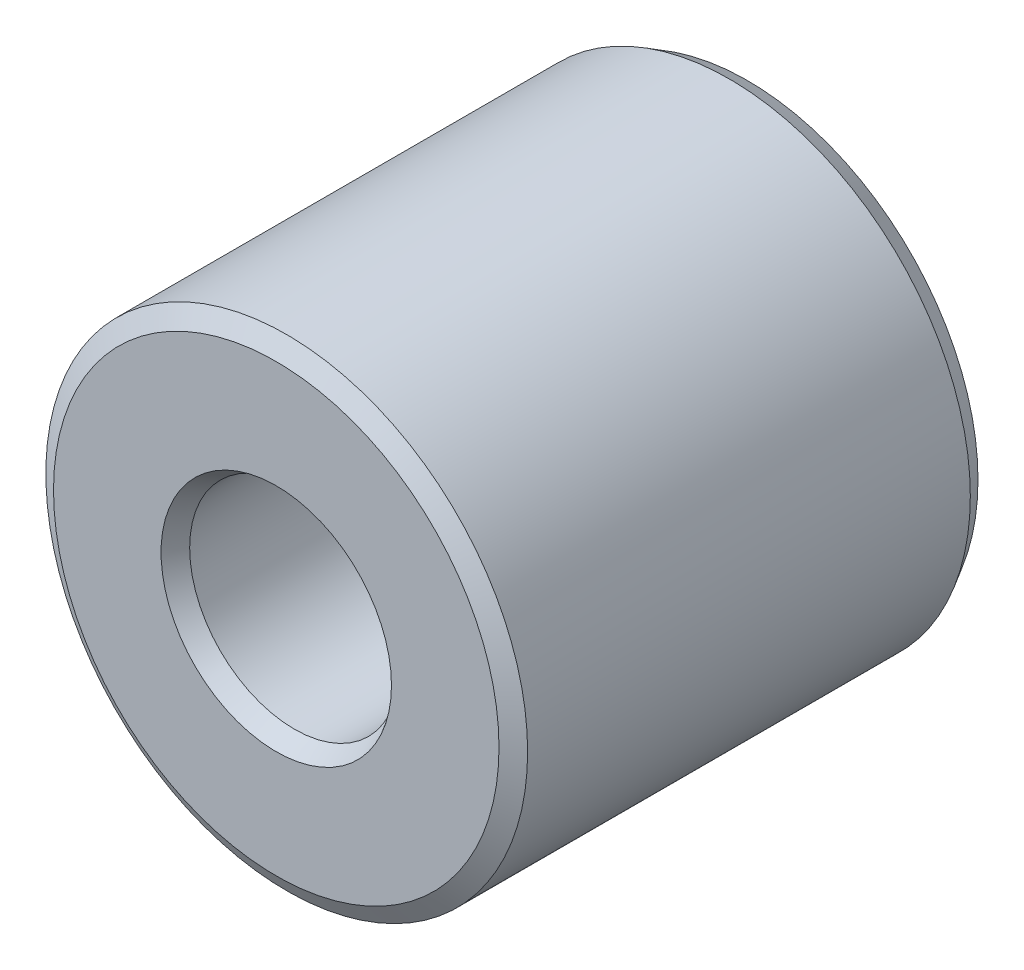
from build123d import *
from OCP.BRepFilletAPI import BRepFilletAPI_MakeChamfer

# Parameters (mm, degrees)
SZKIC1_R                    = 2.3
SZKIC1_R_2                  = 1
DODANIE_WYCI_GNI_CIE1_DEPTH = 4.5
SFAZOWANIE1_SIZE            = 0.1
SFAZOWANIE1_SIZE2           = 0.173205081


with BuildPart() as part:
    # Szkic1 → Dodanie-wyciągnięcie1 (new body)
    with BuildSketch(Plane.XY):
        Circle(SZKIC1_R)
        Circle(SZKIC1_R_2, mode=Mode.SUBTRACT)
    extrude(amount=DODANIE_WYCI_GNI_CIE1_DEPTH)

    # Sfazowanie1: one chamfer whose edges measure the first distance from different faces: ONE call of the kernel's chamfer builder (chamfer() names one face for all edges)
    sfazowanie1_edges_1 = [part.edges().sort_by_distance(p)[0] for p in [
        (-2.3, 0, 0),
    ]]
    sfazowanie1_side_1 = [part.faces().sort_by_distance(p)[0] for p in [
        (-2.234946176, 0, 0),
    ]]
    sfazowanie1_edges_2 = [part.edges().sort_by_distance(p)[0] for p in [
        (-2.3, 0, 4.5),
    ]]
    sfazowanie1_side_2 = [part.faces().sort_by_distance(p)[0] for p in [
        (-2.3, 0, 2.25),
    ]]
    sfazowanie1_edges_3 = [part.edges().sort_by_distance(p)[0] for p in [
        (-1, 0, 0),
    ]]
    sfazowanie1_side_3 = [part.faces().sort_by_distance(p)[0] for p in [
        (-1, 0, 2.25),
    ]]
    sfazowanie1_edges_4 = [part.edges().sort_by_distance(p)[0] for p in [
        (-1, 0, 4.5),
    ]]
    sfazowanie1_side_4 = [part.faces().sort_by_distance(p)[0] for p in [
        (-2.234946176, 0, 4.5),
    ]]
    sfazowanie1 = BRepFilletAPI_MakeChamfer(part.part.solid().wrapped)
    for e in sfazowanie1_edges_1:
        sfazowanie1.Add(SFAZOWANIE1_SIZE, SFAZOWANIE1_SIZE2, e.wrapped, sfazowanie1_side_1[0].wrapped)  # the first distance lies on this face
    for e in sfazowanie1_edges_2:
        sfazowanie1.Add(SFAZOWANIE1_SIZE, SFAZOWANIE1_SIZE2, e.wrapped, sfazowanie1_side_2[0].wrapped)  # the first distance lies on this face
    for e in sfazowanie1_edges_3:
        sfazowanie1.Add(SFAZOWANIE1_SIZE, SFAZOWANIE1_SIZE2, e.wrapped, sfazowanie1_side_3[0].wrapped)  # the first distance lies on this face
    for e in sfazowanie1_edges_4:
        sfazowanie1.Add(SFAZOWANIE1_SIZE, SFAZOWANIE1_SIZE2, e.wrapped, sfazowanie1_side_4[0].wrapped)  # the first distance lies on this face
    add(Compound.cast(sfazowanie1.Shape()), mode=Mode.REPLACE)


solid = part.part
